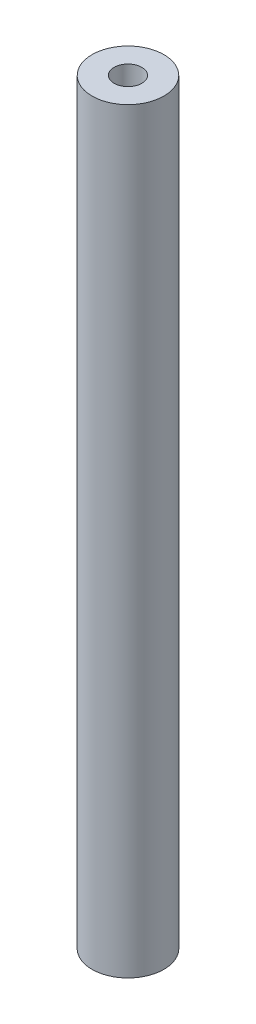
from build123d import *

# Parameters (mm, degrees)
SKETCH1_R           = 3.6195
SKETCH1_R_2         = 1.397
BOSS_EXTRUDE1_DEPTH = 76.2


with BuildPart() as part:
    # Sketch1 → Boss-Extrude1 (new body)
    with BuildSketch(Plane(origin=(0, 0, 0), x_dir=(1, 0, 0), z_dir=(0, 1, 0))):
        Circle(SKETCH1_R)
        Circle(SKETCH1_R_2, mode=Mode.SUBTRACT)
    extrude(amount=BOSS_EXTRUDE1_DEPTH)


solid = part.part
